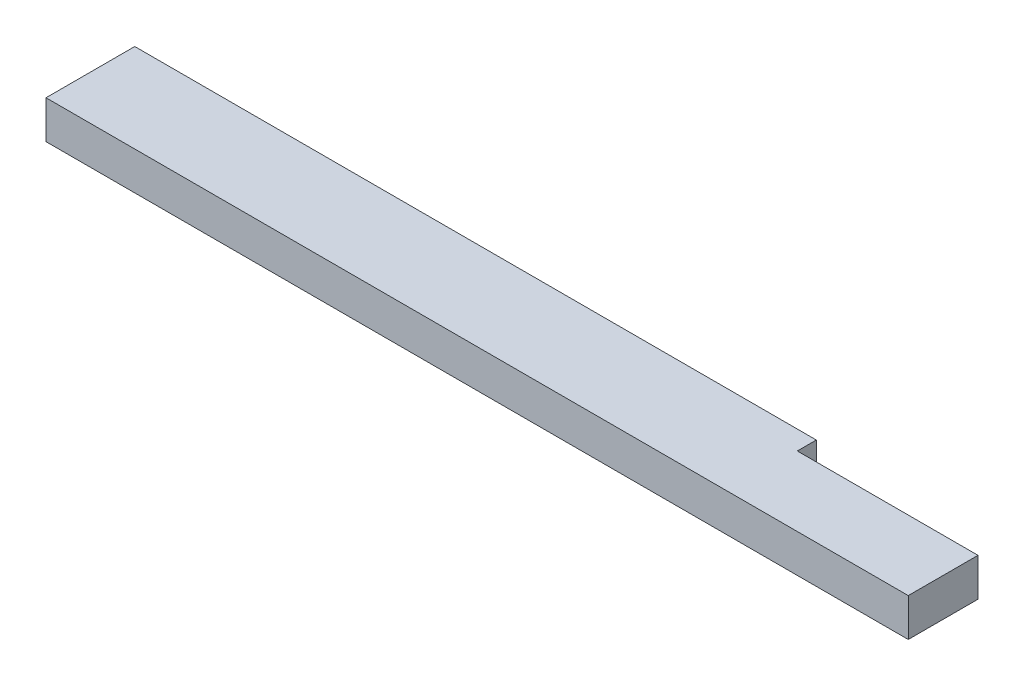
from build123d import *

# Parameters (mm, degrees)
SKETCH1_W           = 863.6
SKETCH1_H           = 88.9
BOSS_EXTRUDE1_DEPTH = 38.1
SKETCH3_W           = 180.975
SKETCH3_H           = 19.05
CUT_EXTRUDE1_DEPTH  = 39.1


with BuildPart() as part:
    # Sketch1 → Boss-Extrude1 (new body)
    with BuildSketch(Plane(origin=(0, 0, 0), x_dir=(1, 0, 0), z_dir=(0, 1, 0))):
        with Locations((431.8, 44.45)):
            Rectangle(SKETCH1_W, SKETCH1_H)
    extrude(amount=BOSS_EXTRUDE1_DEPTH)

    # Sketch3 → Cut-Extrude1 (cut, through all)
    with BuildSketch(Plane(origin=(0, 38.1, 0), x_dir=(1, 0, 0), z_dir=(0, 1, 0))):
        with Locations((773.1125, 79.375)):
            Rectangle(SKETCH3_W, SKETCH3_H)
    extrude(amount=-CUT_EXTRUDE1_DEPTH, mode=Mode.SUBTRACT)


solid = part.part
